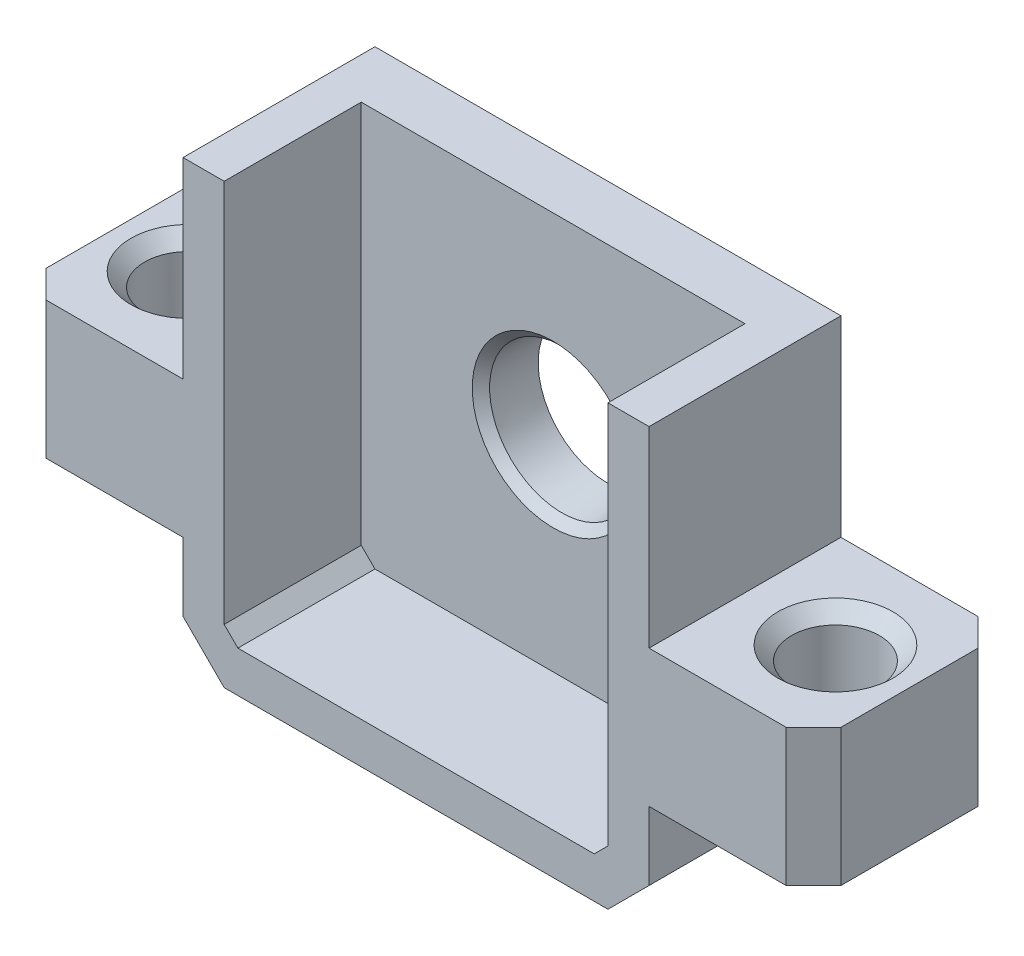
from build123d import *

# Parameters (mm, degrees)
ESQUISSE1_W                  = 17
ESQUISSE1_H                  = 18
BOSS_EXTRU_1_DEPTH           = 2
ESQUISSE2_W                  = 17
ESQUISSE2_H                  = 18
ESQUISSE2_W_2                = 14
ESQUISSE2_H_2                = 15
BOSS_EXTRU_2_DEPTH           = 5
ESQUISSE3_W                  = 7
ESQUISSE3_H                  = 5
BOSS_EXTRU_3_DEPTH           = 6
ESQUISSE4_R                  = 1.6
ENL_V_MAT_EXTRU_1_DEPTH      = 19.445866746
CHANFREIN1_SIZE              = 1
CHANFREIN1_OF_SYM_TRIE2_SIZE = 1
CHANFREIN2_SIZE              = 1.5
CHANFREIN3_SIZE              = 0.5
ESQUISSE5_R                  = 2.65
ENL_V_MAT_EXTRU_2_DEPTH      = 2
ENL_V_MAT_EXTRU_2_DRAFT      = -3
CHANFREIN4_SIZE              = 0.3
CHANFREIN4_SIZE2             = 0.317026351
CHANFREIN5_SIZE              = 0.5
ESQUISSE6_W                  = 25.293651759
ESQUISSE6_H                  = 13.130697886
ENL_V_MAT_EXTRU_3_DEPTH      = 2


with BuildPart() as part:
    # Esquisse1 → Boss.-Extru.1 (new body)
    with BuildSketch(Plane.XY):
        Rectangle(ESQUISSE1_W, ESQUISSE1_H)
    extrude(amount=BOSS_EXTRU_1_DEPTH)

    # Esquisse2 → Boss.-Extru.2 (add)
    with BuildSketch(Plane.XY.offset(2)):
        Rectangle(ESQUISSE2_W, ESQUISSE2_H)
        Rectangle(ESQUISSE2_W_2, ESQUISSE2_H_2, mode=Mode.SUBTRACT)
    extrude(amount=BOSS_EXTRU_2_DEPTH)

    # Esquisse3 → Boss.-Extru.3 (add)
    with BuildSketch(Plane.ZY.offset(8.5)):
        with Locations((3.5, -2.5)):
            Rectangle(ESQUISSE3_W, ESQUISSE3_H)
    boss_extru_3 = extrude(amount=BOSS_EXTRU_3_DEPTH)

    # Esquisse4 → Enlèv. mat.-Extru.1 (cut, through all)
    with BuildSketch(Plane(origin=(0, 0, 0), x_dir=(1, 0, 0), z_dir=(0, 1, 0))):
        with Locations(Location((-11.8, -3.5, 0), (0, 0, 270))):
            Circle(ESQUISSE4_R)
    enl_v_mat_extru_1 = extrude(amount=-ENL_V_MAT_EXTRU_1_DEPTH, mode=Mode.SUBTRACT)

    # Chanfrein1
    chanfrein1_edges = [part.edges().sort_by_distance(p)[0] for p in [
        (-14.5, -2.5, 0),
        (-14.5, -2.5, 7),
    ]]
    chamfer(chanfrein1_edges, length=CHANFREIN1_SIZE)

    # Symétrie2: Boss.-Extru.3, Enlèv. mat.-Extru.1 across plane
    add(boss_extru_3.mirror(Plane(origin=(0, 0, 0), x_dir=(0, 0, 1), z_dir=(1, 0, 0))))
    add(enl_v_mat_extru_1.mirror(Plane(origin=(0, 0, 0), x_dir=(0, 0, 1), z_dir=(1, 0, 0))), mode=Mode.SUBTRACT)

    # Chanfrein1 of Symétrie2
    chanfrein1_of_sym_trie2_edges = [part.edges().sort_by_distance(p)[0] for p in [
        (14.5, -2.5, 0),
        (14.5, -2.5, 7),
    ]]
    chamfer(chanfrein1_of_sym_trie2_edges, length=CHANFREIN1_OF_SYM_TRIE2_SIZE)

    # Chanfrein2
    chanfrein2_edges = [part.edges().sort_by_distance(p)[0] for p in [
        (-8.5, 9, 3.5),
        (8.5, 9, 3.5),
        (8.5, -9, 3.5),
        (-8.5, -9, 3.5),
    ]]
    chamfer(chanfrein2_edges, length=CHANFREIN2_SIZE)

    # Chanfrein3
    chanfrein3_edges = [part.edges().sort_by_distance(p)[0] for p in [
        (-7, -7.5, 4.5),
        (7, -7.5, 4.5),
        (7, 7.5, 4.5),
        (-7, 7.5, 4.5),
    ]]
    chamfer(chanfrein3_edges, length=CHANFREIN3_SIZE)


with BuildPart() as enl_v_mat_extru_2_tool:
    # Esquisse5 → Enlèv. mat.-Extru.2 (with draft: the straight prism first)
    with BuildSketch(Plane.XY.offset(2)):
        Circle(ESQUISSE5_R)
    extrude(amount=-ENL_V_MAT_EXTRU_2_DEPTH)
    # Enlèv. mat.-Extru.2: the draft: its side faces are tilted about the plane it starts from
    enl_v_mat_extru_2_sides = [enl_v_mat_extru_2_tool.faces().sort_by_distance(p)[0] for p in [
        (-2.65, 0, 1),
    ]]
    draft(enl_v_mat_extru_2_sides, Plane.XY.offset(2), ENL_V_MAT_EXTRU_2_DRAFT)


with BuildPart() as part_1:
    add(part.part)

    # Enlèv. mat.-Extru.2: cut by enl_v_mat_extru_2_tool
    add(enl_v_mat_extru_2_tool.part, mode=Mode.SUBTRACT)

    # Chanfrein4
    chanfrein4_edges = [part_1.edges().sort_by_distance(p)[0] for p in [
        (-2.65, 0, 2),
    ]]
    chanfrein4_side = [part_1.faces().sort_by_distance(p)[0] for p in [
        (0, -7.294817155, 2),
    ]]
    chamfer(chanfrein4_edges, length=CHANFREIN4_SIZE, length2=CHANFREIN4_SIZE2, reference=chanfrein4_side[0])

    # Chanfrein5
    chanfrein5_edges = [part_1.edges().sort_by_distance(p)[0] for p in [
        (-11.8, 0, 1.9),
        (11.8, 0, 1.9),
    ]]
    chamfer(chanfrein5_edges, length=CHANFREIN5_SIZE)

    # Esquisse6 → Enlèv. mat.-Extru.3 (cut)
    with BuildSketch(Plane(origin=(0, 9, 0), x_dir=(1, 0, 0), z_dir=(0, 1, 0))):
        with Locations((1.808818071, -4.181872969)):
            Rectangle(ESQUISSE6_W, ESQUISSE6_H)
    extrude(amount=-ENL_V_MAT_EXTRU_3_DEPTH, mode=Mode.SUBTRACT)


solid = part_1.part
